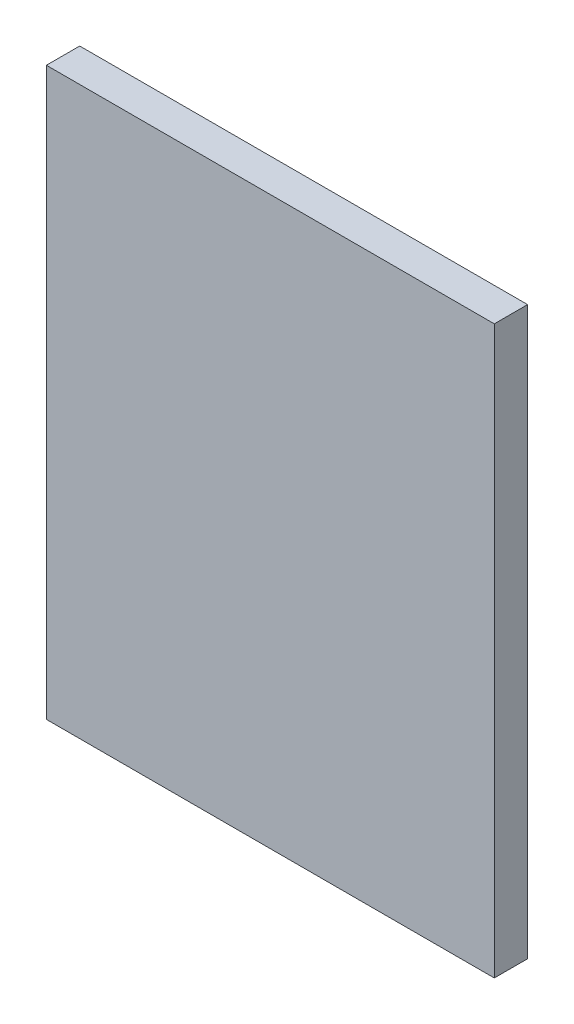
from build123d import *

# Parameters (mm, degrees)
SKETCH2_W           = 42.672
SKETCH2_H           = 53.975
BOSS_EXTRUDE1_DEPTH = 1.5875


with BuildPart() as part:
    # Sketch2 → Boss-Extrude1 (new body, symmetric)
    with BuildSketch(Plane.XY):
        Rectangle(SKETCH2_W, SKETCH2_H)
    extrude(amount=BOSS_EXTRUDE1_DEPTH, both=True)


solid = part.part
